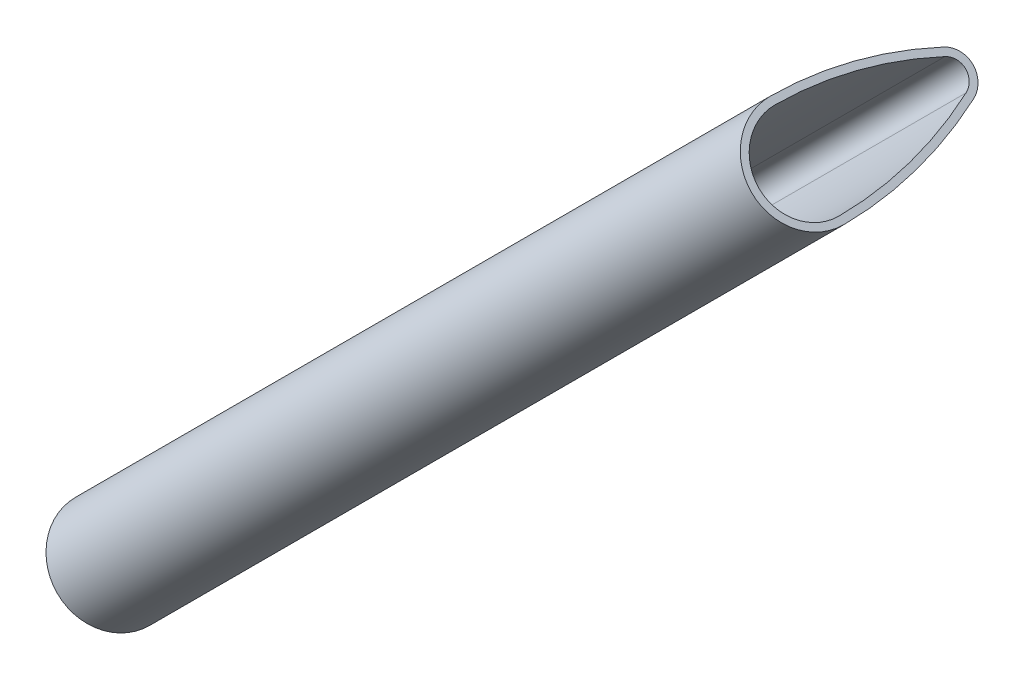
from build123d import *

# Parameters (mm, degrees)
BOSS_EXTRUDE1_DEPTH = 96.674201326


with BuildPart() as part:
    # Sketch1 → Boss-Extrude1 (new body)
    with BuildSketch(Plane(origin=(33.08614304, 33.08614304, 4.093670875), x_dir=(0.707106781, -0.707106781, 0), z_dir=(-0.704416026, -0.704416026, -0.087155743))):
        with BuildLine():
            ThreePointArc((-4.50000347, -19.614075699), (-3.815448832, -25.917485875), (-1.82137714, -31.936229348))
            ThreePointArc((-1.82137714, -31.936229348), (8.178e-06, -33.110098509), (1.821383894, -31.936214448))
            ThreePointArc((1.821383894, -31.936214448), (3.815427721, -25.917468388), (4.50000349, -19.614066852))
            ThreePointArc((4.50000349, -19.614066852), (-4.417e-06, -15.110036834), (-4.50000347, -19.614075699))
        make_face()
        with BuildLine():
            ThreePointArc((1.274961922, -31.68837775), (-8e-09, -32.510085588), (-1.274961931, -31.688377739))
            ThreePointArc((-1.274961931, -31.688377739), (-3.22841338, -25.793381652), (-3.8999884, -19.619570962))
            ThreePointArc((-3.8999884, -19.619570962), (-0.003114143, -15.70968365), (3.900003566, -19.613338337))
            ThreePointArc((3.900003566, -19.613338337), (3.229075576, -25.790336504), (1.274961922, -31.68837775))
        make_face(mode=Mode.SUBTRACT)
    extrude(amount=-BOSS_EXTRUDE1_DEPTH)


solid = part.part
